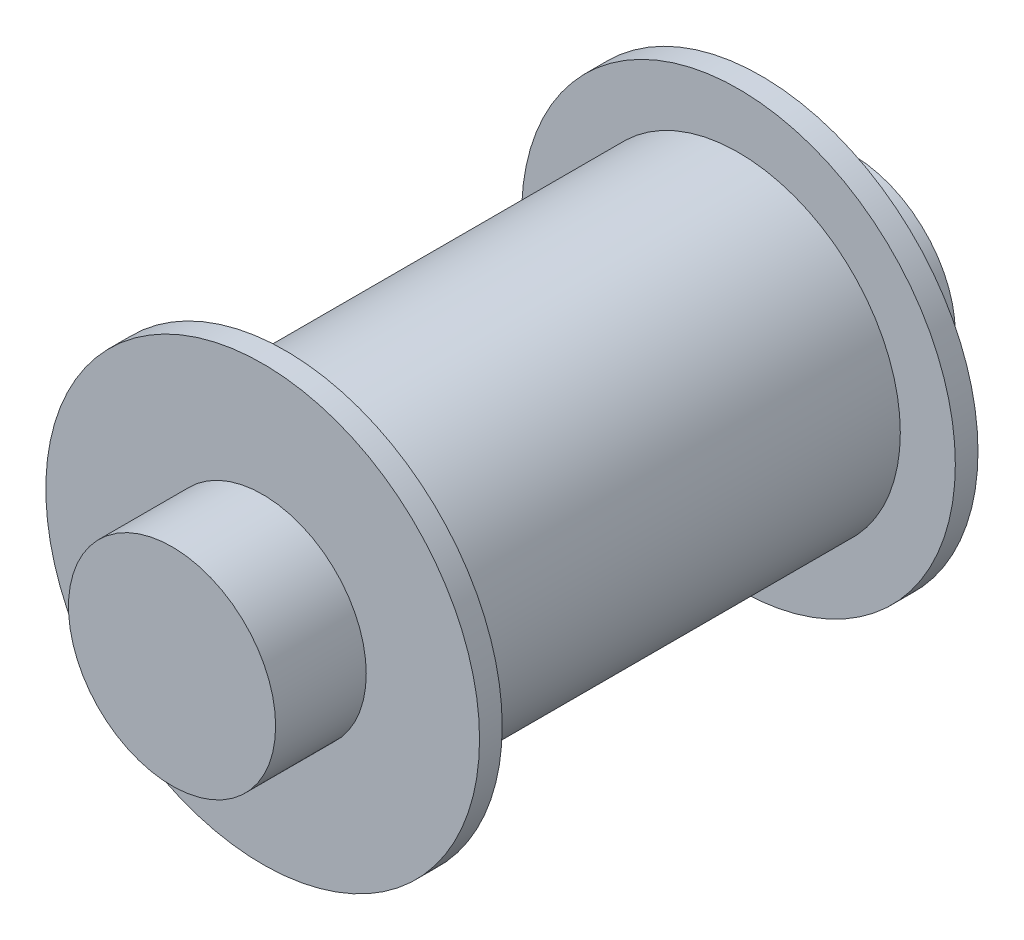
from build123d import *


with BuildPart() as part:
    # Sketch1 → Revolve1 (revolve)
    with BuildSketch(Plane(origin=(0, 0, 0), x_dir=(0, 0, -1), z_dir=(1, 0, 0))):
        Polygon((-38.5, 0), (38.5, 0), (52.5, 0), (52.5, 16), (38.5, 16), (38.5, 33.5), (35, 33.5), (35, 25), (-35, 25), (-35, 33.5), (-38.5, 33.5), (-38.5, 16), (-52.5, 16), (-52.5, 0), align=None)
    revolve(axis=Axis((0, 0, 0), (0, 0, -1)))


solid = part.part
